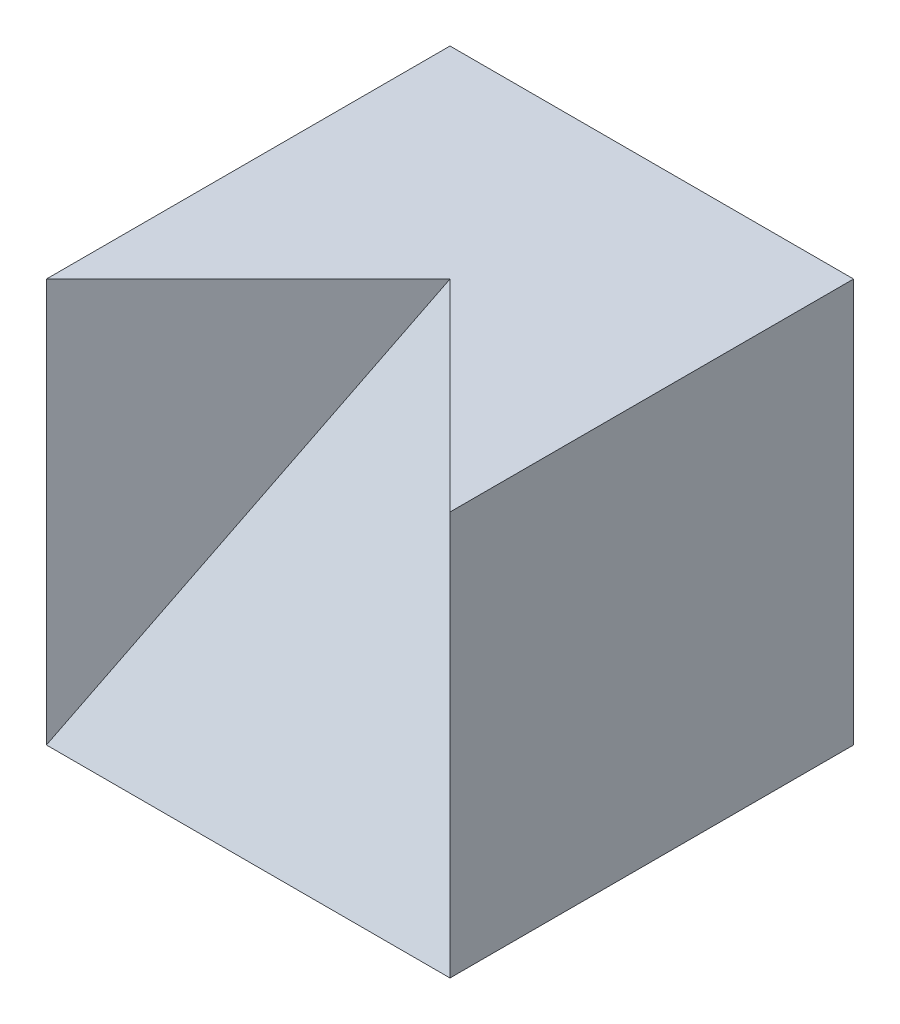
from build123d import *

# Parameters (mm, degrees)
SKETCH2_W           = 4
SKETCH2_H           = 4
BOSS_EXTRUDE1_DEPTH = 4
CUT_EXTRUDE1_DEPTH  = 4


with BuildPart() as part:
    # Sketch2 → Boss-Extrude1 (new body)
    with BuildSketch(Plane(origin=(0, 0, 0), x_dir=(1, 0, 0), z_dir=(0, 1, 0))):
        Rectangle(SKETCH2_W, SKETCH2_H)
    extrude(amount=BOSS_EXTRUDE1_DEPTH)

    # 3DSketch1 → Cut-Extrude1 (cut, along a direction that is not the sketch's normal)
    with BuildSketch(Plane(origin=(2, 0, 2), x_dir=(-0.4082482904638631, 0.8164965809277261, -0.4082482904638631), z_dir=(0, 0.447213595499958, 0.894427190999916))):
        Polygon((0, 0), (4.898979486, 0), (1.632993162, 3.651483717), align=None)
    extrude(amount=CUT_EXTRUDE1_DEPTH, dir=(0, 1, 0), mode=Mode.SUBTRACT)


solid = part.part
